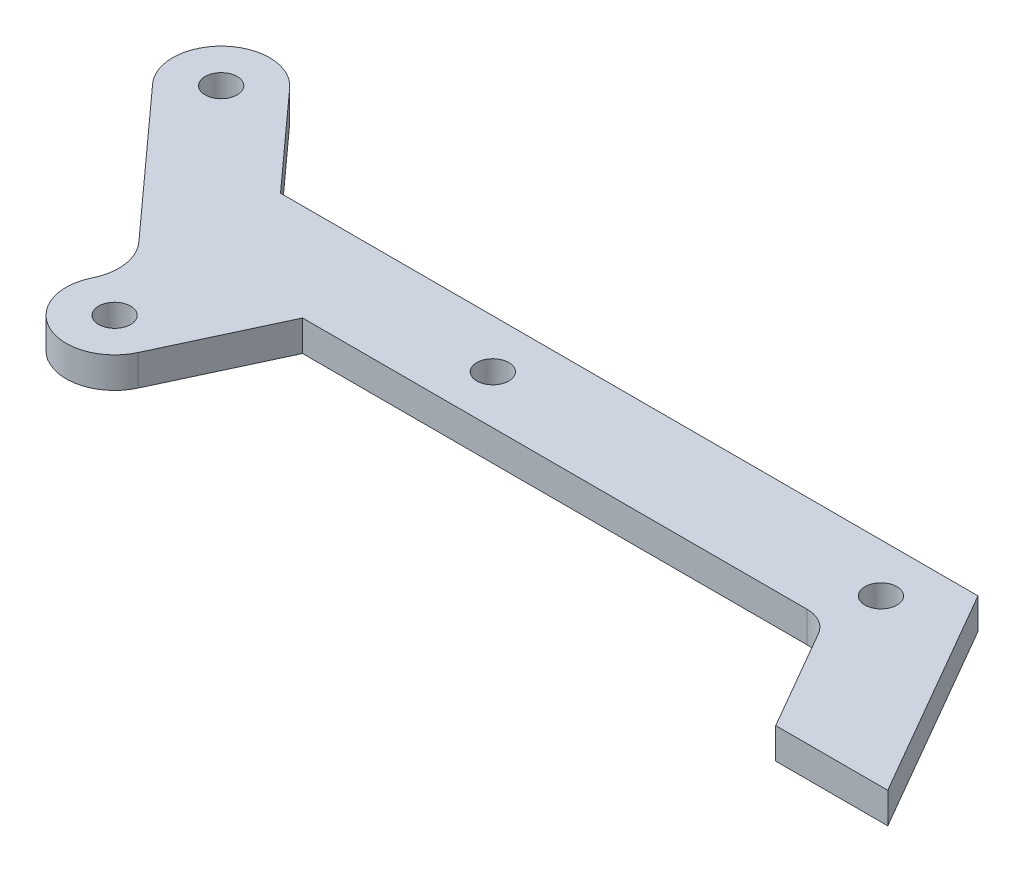
from build123d import *

# Parameters (mm, degrees)
BOSS_EXTRUDE1_DEPTH   = 1.5875
M4X0_7_TAPPED_HOLE1_D = 3.3
M4X0_7_TAPPED_HOLE2_D = 3.3


with BuildPart() as part:
    # Sketch1 → Boss-Extrude1 (new body, symmetric)
    with BuildSketch(Plane(origin=(0, 0, 0), x_dir=(1, 0, 0), z_dir=(0, 1, 0))):
        with BuildLine():
            Line((0, 0), (-11.547005384, 0))
            Line((-11.547005384, 0), (-17.558665062, 10.4125))
            ThreePointArc((-17.558665062, 10.4125), (-18.720795719, 11.574630657), (-20.308295719, 12))
            Line((-20.308295719, 12), (-72.308295719, 12))
            Line((-72.308295719, 12), (-77.698457708, 0.440760311))
            ThreePointArc((-77.698457708, 0.440760311), (-84.343088233, -1.977687418), (-86.761535579, 4.666942928))
            Line((-86.761535579, 4.666942928), (-86.675516364, 4.851411729))
            ThreePointArc((-86.675516364, 4.851411729), (-86.262765717, 7.708815155), (-87.498464442, 10.318061424))
            Line((-87.498464442, 10.318061424), (-100.938587731, 25.181055478))
            ThreePointArc((-100.938587731, 25.181055478), (-100.583555179, 32.243204718), (-93.521405939, 31.888172166))
            Line((-93.521405939, 31.888172166), (-84.579852673, 22))
            Line((-84.579852673, 22), (-12.701705922, 22))
            Line((-12.701705922, 22), (0, 0))
        make_face()
    extrude(amount=BOSS_EXTRUDE1_DEPTH, both=True)

    # M4x0.7 Tapped Hole1 (through all)
    with Locations(Plane(origin=(0, 1.5875, 0), x_dir=(1, 0, 0), z_dir=(0, 1, 0))):
        with Locations((-17.701705922, 17), (-57.701705922, 17)):
            Hole(M4X0_7_TAPPED_HOLE1_D / 2)

    # M4x0.7 Tapped Hole2 (through all)
    with Locations(Plane(origin=(0, 1.5875, 0), x_dir=(1, 0, 0), z_dir=(0, 1, 0))):
        with Locations((-82.229996835, 2.553851709), (-97.229996835, 28.534613822)):
            Hole(M4X0_7_TAPPED_HOLE2_D / 2)


solid = part.part
